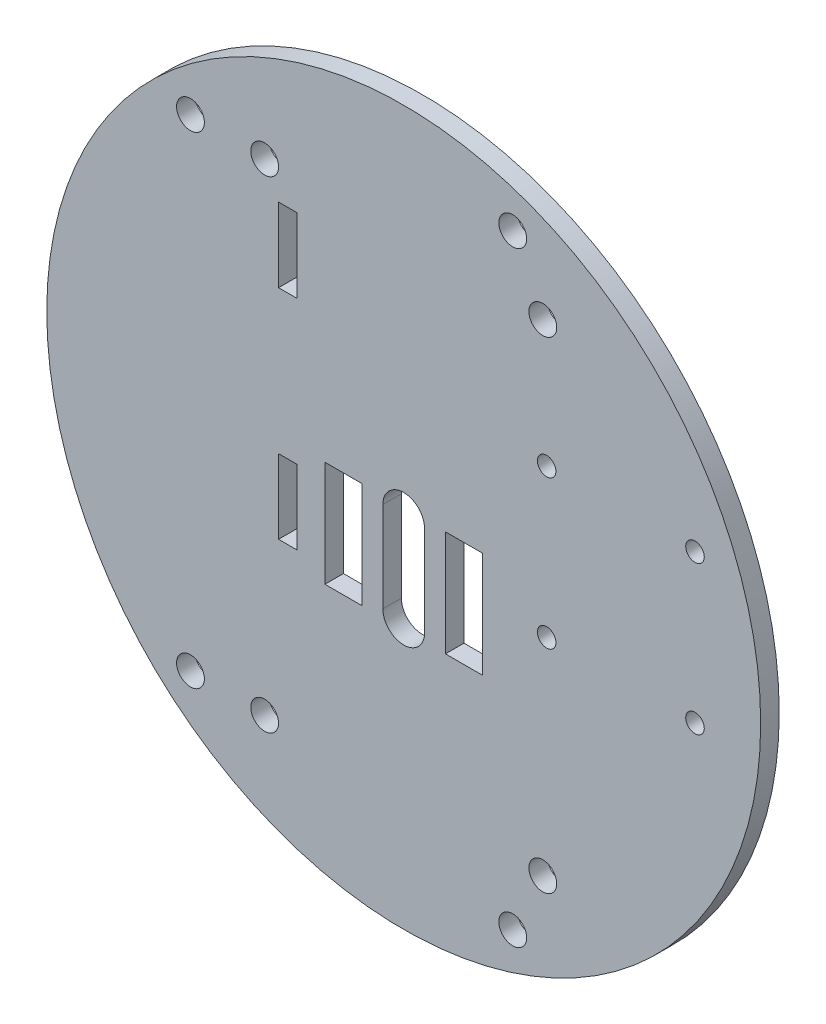
from build123d import *

# Parameters (mm, degrees)
MODEL_R             = 38.5
MODEL_R_2           = 1.5
MODEL_R_3           = 1
MODEL_W             = 2
MODEL_H             = 8
MODEL_W_2           = 4
MODEL_H_2           = 11.4
BOSS_EXTRUDE1_DEPTH = 2


with BuildPart() as part:
    # Model → Boss-Extrude1 (new body)
    with BuildSketch(Plane.XY):
        with Locations((0, -0.073397172)):
            Circle(MODEL_R)
        with Locations((-23, 26.05)):
            Circle(MODEL_R_2, mode=Mode.SUBTRACT)
        with Locations((11.757144545, -32.719523315)):
            Circle(MODEL_R_2, mode=Mode.SUBTRACT)
        with Locations((11.757144545, 32.572728971)):
            Circle(MODEL_R_2, mode=Mode.SUBTRACT)
        with Locations((31.414701296, 12.426602828)):
            Circle(MODEL_R_3, mode=Mode.SUBTRACT)
        with Locations((31.414701296, -3.573397172)):
            Circle(MODEL_R_3, mode=Mode.SUBTRACT)
        with Locations((15.414701296, 12.426602828)):
            Circle(MODEL_R_3, mode=Mode.SUBTRACT)
        with Locations((15.414701296, -3.573397172)):
            Circle(MODEL_R_3, mode=Mode.SUBTRACT)
        with Locations((-23, -25.91)):
            Circle(MODEL_R_2, mode=Mode.SUBTRACT)
        with Locations((-15, -26.054159286)):
            Circle(MODEL_R_2, mode=Mode.SUBTRACT)
        with Locations((15, 25.907364941)):
            Circle(MODEL_R_2, mode=Mode.SUBTRACT)
        with Locations((-15, 25.907364941)):
            Circle(MODEL_R_2, mode=Mode.SUBTRACT)
        with Locations((15, -26.054159286)):
            Circle(MODEL_R_2, mode=Mode.SUBTRACT)
        with Locations((-12.5, -4.873397172)):
            Rectangle(MODEL_W, MODEL_H, mode=Mode.SUBTRACT)
        with Locations((-12.5, 18.626602828)):
            Rectangle(MODEL_W, MODEL_H, mode=Mode.SUBTRACT)
        with Locations((-6.5, -4.873397172)):
            Rectangle(MODEL_W_2, MODEL_H_2, mode=Mode.SUBTRACT)
        with Locations((6.5, -4.873397172)):
            Rectangle(MODEL_W_2, MODEL_H_2, mode=Mode.SUBTRACT)
        with BuildLine():
            Line((-2.25, 0), (-2.25, -9.746794345))
            ThreePointArc((-2.25, -9.746794345), (0, -11.996794345), (2.25, -9.746794345))
            Line((2.25, -9.746794345), (2.25, 0))
            ThreePointArc((2.25, 0), (0, 2.25), (-2.25, 0))
        make_face(mode=Mode.SUBTRACT)
    extrude(amount=BOSS_EXTRUDE1_DEPTH)


solid = part.part
